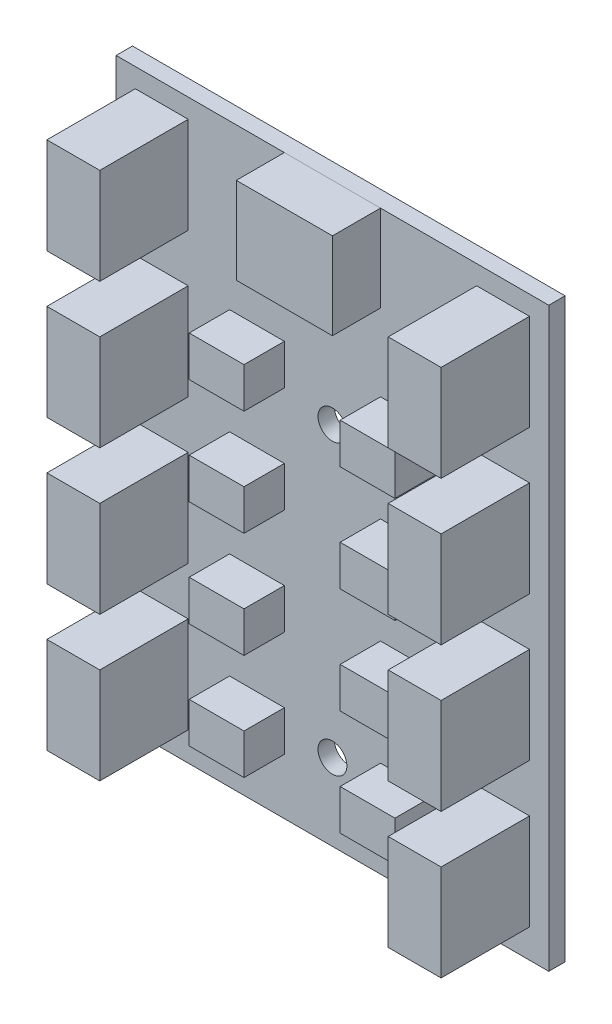
from build123d import *

# Parameters (mm, degrees)
SKETCH_1_W        = 45
SKETCH_1_H        = 60
SKETCH_1_R        = 1.5
EXTRUDE_379_DEPTH = 1.7
SKETCH_2_W        = 10
SKETCH_2_H        = 9
XT30_DEPTH        = 5
SKETCH_3_W        = 5.5
SKETCH_3_H        = 10
XT30_2_DEPTH      = 9.2
XT30_2_2_DEPTH    = 9.2
XT30_2_3_DEPTH    = 9.2
XT30_2_4_DEPTH    = 9.2
XT30_2_5_DEPTH    = 9.2
XT30_2_6_DEPTH    = 9.2
XT30_2_7_DEPTH    = 9.2
XT30_2_8_DEPTH    = 9.2
SKETCH_4_W        = 5.7
SKETCH_4_H        = 4.2
CAN_DEPTH         = 4.2
CAN_2_DEPTH       = 4.2
CAN_3_DEPTH       = 4.2
CAN_4_DEPTH       = 4.2
CAN_5_DEPTH       = 4.2
CAN_6_DEPTH       = 4.2
CAN_7_DEPTH       = 4.2
CAN_8_DEPTH       = 4.2


with BuildPart() as part:
    # 草图1 → Extrude 379 (new body)
    with BuildSketch(Plane.XY):
        Rectangle(SKETCH_1_W, SKETCH_1_H)
        with Locations((0, -22)):
            Circle(SKETCH_1_R, mode=Mode.SUBTRACT)
        with Locations((0, 8)):
            Circle(SKETCH_1_R, mode=Mode.SUBTRACT)
    extrude(amount=EXTRUDE_379_DEPTH)


with BuildPart() as body_2:
    # 草图2 → xt30 (new body)
    with BuildSketch(Plane.XY.offset(1.7)):
        with Locations((0, 25.5)):
            Rectangle(SKETCH_2_W, SKETCH_2_H)
    extrude(amount=XT30_DEPTH)


with BuildPart() as body_3:
    # 草图3 → xt30 2 (new body)
    with BuildSketch(Plane.XY.offset(1.7)):
        with Locations((-17.75, 23)):
            Rectangle(SKETCH_3_W, SKETCH_3_H)
    extrude(amount=XT30_2_DEPTH)


with BuildPart() as body_4:
    # 草图3 → xt30 2 2 (new body)
    with BuildSketch(Plane.XY.offset(1.7)):
        with Locations((-17.75, 8)):
            Rectangle(SKETCH_3_W, SKETCH_3_H)
    extrude(amount=XT30_2_2_DEPTH)


with BuildPart() as body_5:
    # 草图3 → xt30 2 3 (new body)
    with BuildSketch(Plane.XY.offset(1.7)):
        with Locations((-17.75, -7)):
            Rectangle(SKETCH_3_W, SKETCH_3_H)
    extrude(amount=XT30_2_3_DEPTH)


with BuildPart() as body_6:
    # 草图3 → xt30 2 4 (new body)
    with BuildSketch(Plane.XY.offset(1.7)):
        with Locations((-17.75, -22)):
            Rectangle(SKETCH_3_W, SKETCH_3_H)
    extrude(amount=XT30_2_4_DEPTH)


with BuildPart() as body_7:
    # 草图3 → xt30 2 5 (new body)
    with BuildSketch(Plane.XY.offset(1.7)):
        with Locations((17.75, -22)):
            Rectangle(SKETCH_3_W, SKETCH_3_H)
    extrude(amount=XT30_2_5_DEPTH)


with BuildPart() as body_8:
    # 草图3 → xt30 2 6 (new body)
    with BuildSketch(Plane.XY.offset(1.7)):
        with Locations((17.75, -7)):
            Rectangle(SKETCH_3_W, SKETCH_3_H)
    extrude(amount=XT30_2_6_DEPTH)


with BuildPart() as body_9:
    # 草图3 → xt30 2 7 (new body)
    with BuildSketch(Plane.XY.offset(1.7)):
        with Locations((17.75, 8)):
            Rectangle(SKETCH_3_W, SKETCH_3_H)
    extrude(amount=XT30_2_7_DEPTH)


with BuildPart() as body_10:
    # 草图3 → xt30 2 8 (new body)
    with BuildSketch(Plane.XY.offset(1.7)):
        with Locations((17.75, 23)):
            Rectangle(SKETCH_3_W, SKETCH_3_H)
    extrude(amount=XT30_2_8_DEPTH)


with BuildPart() as body_11:
    # 草图4 → can (new body)
    with BuildSketch(Plane.XY.offset(1.7)):
        with Locations((-7.85, 10.9)):
            Rectangle(SKETCH_4_W, SKETCH_4_H)
    extrude(amount=CAN_DEPTH)


with BuildPart() as body_12:
    # 草图4 → can 2 (new body)
    with BuildSketch(Plane.XY.offset(1.7)):
        with Locations((-7.85, -0.1)):
            Rectangle(SKETCH_4_W, SKETCH_4_H)
    extrude(amount=CAN_2_DEPTH)


with BuildPart() as body_13:
    # 草图4 → can 3 (new body)
    with BuildSketch(Plane.XY.offset(1.7)):
        with Locations((-7.85, -11.1)):
            Rectangle(SKETCH_4_W, SKETCH_4_H)
    extrude(amount=CAN_3_DEPTH)


with BuildPart() as body_14:
    # 草图4 → can 4 (new body)
    with BuildSketch(Plane.XY.offset(1.7)):
        with Locations((-7.85, -22.1)):
            Rectangle(SKETCH_4_W, SKETCH_4_H)
    extrude(amount=CAN_4_DEPTH)


with BuildPart() as body_15:
    # 草图4 → can 5 (new body)
    with BuildSketch(Plane.XY.offset(1.7)):
        with Locations((7.85, -22.1)):
            Rectangle(SKETCH_4_W, SKETCH_4_H)
    extrude(amount=CAN_5_DEPTH)


with BuildPart() as body_16:
    # 草图4 → can 6 (new body)
    with BuildSketch(Plane.XY.offset(1.7)):
        with Locations((7.85, -11.1)):
            Rectangle(SKETCH_4_W, SKETCH_4_H)
    extrude(amount=CAN_6_DEPTH)


with BuildPart() as body_17:
    # 草图4 → can 7 (new body)
    with BuildSketch(Plane.XY.offset(1.7)):
        with Locations((7.85, -0.1)):
            Rectangle(SKETCH_4_W, SKETCH_4_H)
    extrude(amount=CAN_7_DEPTH)


with BuildPart() as body_18:
    # 草图4 → can 8 (new body)
    with BuildSketch(Plane.XY.offset(1.7)):
        with Locations((7.85, 10.9)):
            Rectangle(SKETCH_4_W, SKETCH_4_H)
    extrude(amount=CAN_8_DEPTH)


solid = Compound([part.part, body_2.part, body_3.part, body_4.part, body_5.part, body_6.part, body_7.part, body_8.part, body_9.part, body_10.part, body_11.part, body_12.part, body_13.part, body_14.part, body_15.part, body_16.part, body_17.part, body_18.part])
